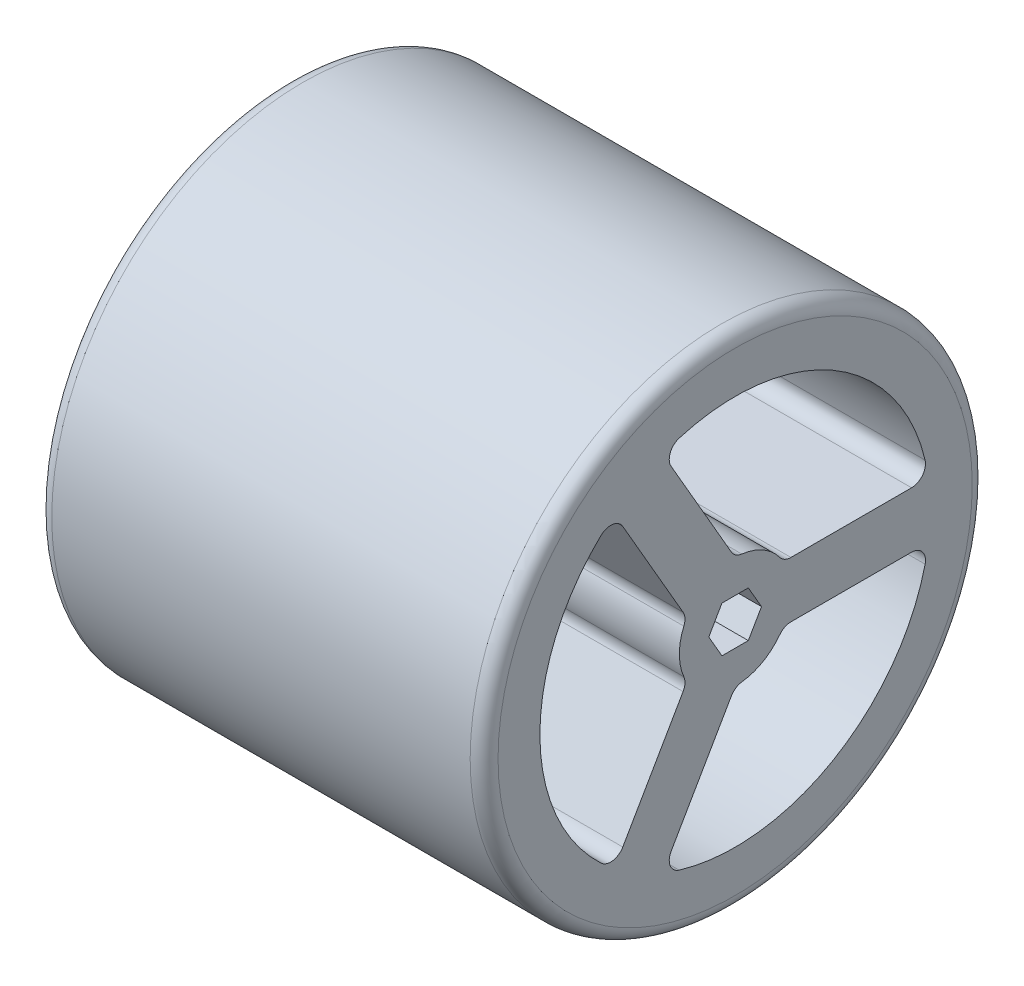
from build123d import *

# Parameters (mm, degrees)
SKETCH1_R           = 14.2875
BOSS_EXTRUDE1_DEPTH = 12.7
FILLET1_R           = 0.79375


with BuildPart() as part:
    # Sketch1 → Boss-Extrude1 (new body, symmetric)
    with BuildSketch(Plane(origin=(0, 0, 0), x_dir=(0, 0, -1), z_dir=(1, 0, 0))):
        Circle(SKETCH1_R)
        Polygon((0.75, -1.299038106), (1.5, 0), (0.75, 1.299038106), (-0.75, 1.299038106), (-1.5, 0), (-0.75, -1.299038106), align=None, mode=Mode.SUBTRACT)
        with BuildLine():
            Line((3.175, 1.5875), (10.040231571, 1.5875))
            ThreePointArc((10.040231571, 1.5875), (10.6629003, 1.888987147), (10.812557076, 2.564423077))
            ThreePointArc((10.812557076, 2.564423077), (5.55625, 9.6237073), (-3.185423008, 10.646160647))
            ThreePointArc((-3.185423008, 10.646160647), (-3.695539293, 10.178836111), (-3.645300457, 9.4888456))
            Line((-3.645300457, 9.4888456), (-0.212684671, 3.543380657))
            ThreePointArc((-0.212684671, 3.543380657), (0.037374782, 3.277861812), (0.379778394, 3.152204526))
            ThreePointArc((0.379778394, 3.152204526), (1.5875, 2.749630657), (2.54, 1.905))
            ThreePointArc((2.54, 1.905), (2.820024209, 1.671298417), (3.175, 1.5875))
        make_face(mode=Mode.SUBTRACT)
        with BuildLine():
            Line((3.175, -1.5875), (10.040231571, -1.5875))
            ThreePointArc((10.040231571, -1.5875), (10.6629003, -1.888987147), (10.812557076, -2.564423077))
            ThreePointArc((10.812557076, -2.564423077), (5.55625, -9.6237073), (-3.185423008, -10.646160647))
            ThreePointArc((-3.185423008, -10.646160647), (-3.695539293, -10.178836111), (-3.645300457, -9.4888456))
            Line((-3.645300457, -9.4888456), (-0.212684671, -3.543380657))
            ThreePointArc((-0.212684671, -3.543380657), (0.037374782, -3.277861812), (0.379778394, -3.152204526))
            ThreePointArc((0.379778394, -3.152204526), (1.5875, -2.749630657), (2.54, -1.905))
            ThreePointArc((2.54, -1.905), (2.820024209, -1.671298417), (3.175, -1.5875))
        make_face(mode=Mode.SUBTRACT)
        with BuildLine():
            Line((-2.962315329, -1.955880657), (-6.394931114, -7.9013456))
            ThreePointArc((-6.394931114, -7.9013456), (-6.967361007, -8.289848964), (-7.627134069, -8.08173757))
            ThreePointArc((-7.627134069, -8.08173757), (-11.1125, 0), (-7.627134069, 8.08173757))
            ThreePointArc((-7.627134069, 8.08173757), (-6.967361007, 8.289848964), (-6.394931114, 7.9013456))
            Line((-6.394931114, 7.9013456), (-2.962315329, 1.955880657))
            ThreePointArc((-2.962315329, 1.955880657), (-2.857398991, 1.606563395), (-2.919778394, 1.247204526))
            ThreePointArc((-2.919778394, 1.247204526), (-3.175, 0), (-2.919778394, -1.247204526))
            ThreePointArc((-2.919778394, -1.247204526), (-2.857398991, -1.606563395), (-2.962315329, -1.955880657))
        make_face(mode=Mode.SUBTRACT)
    extrude(amount=BOSS_EXTRUDE1_DEPTH, both=True)

    # Fillet1
    fillet1_edges = [part.edges().sort_by_distance(p)[0] for p in [
        (-12.7, 0, 14.2875),
        (12.7, 0, 14.2875),
    ]]
    fillet(fillet1_edges, radius=FILLET1_R)


solid = part.part
